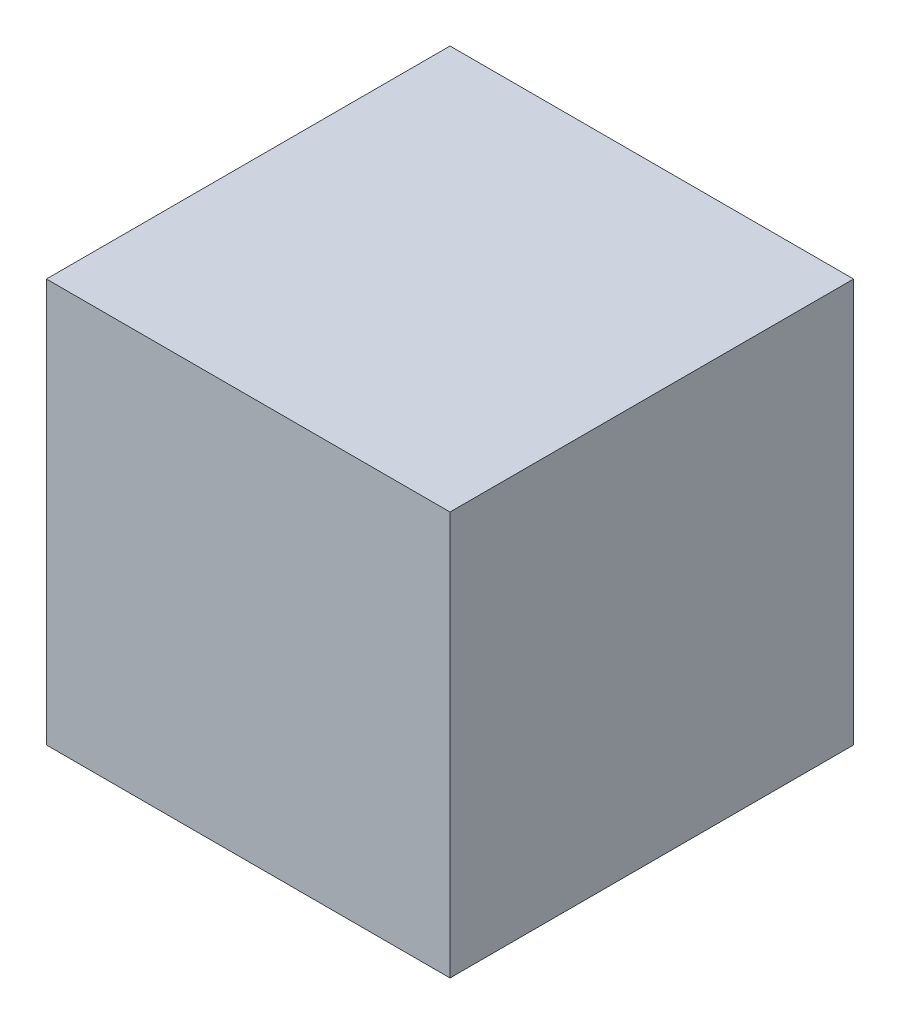
from build123d import *

# Parameters (mm, degrees)
SKETCH1_W           = 10
SKETCH1_H           = 10
BOSS_EXTRUDE1_DEPTH = 10


with BuildPart() as part:
    # Sketch1 → Boss-Extrude1 (new body)
    with BuildSketch(Plane(origin=(0, 0, 0), x_dir=(1, 0, 0), z_dir=(0, 1, 0))):
        with Locations((5, 5)):
            Rectangle(SKETCH1_W, SKETCH1_H)
    extrude(amount=BOSS_EXTRUDE1_DEPTH)


solid = part.part
